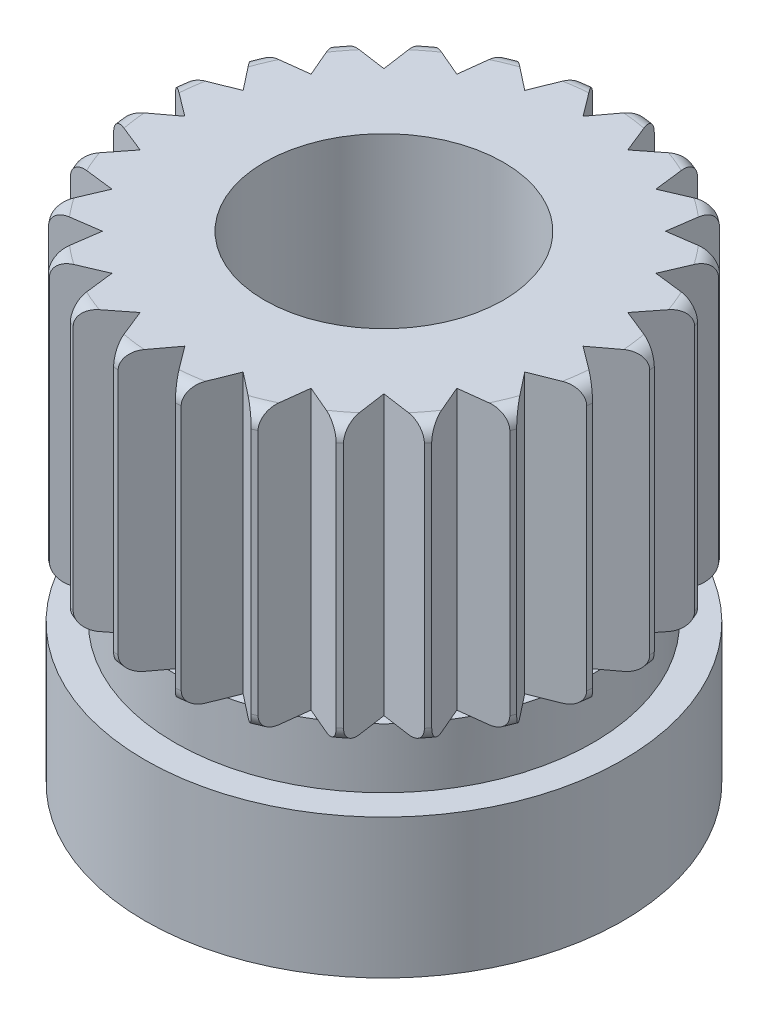
from build123d import *

# Parameters (mm, degrees)
FILLET4_R          = 0.2
CUT_EXTRUDE3_DEPTH = 3.5
CIRPATTERN1_COUNT  = 24
SKETCH3_R          = 1.5
CUT_EXTRUDE4_DEPTH = 8


with BuildPart() as part:
    # Sketch1 → Revolve1 (revolve)
    with BuildSketch(Plane.XY):
        Polygon((12.846617857, 60.731926631), (9.846617857, 60.731926631), (9.846617857, 54.731926631), (12.846617857, 54.731926631), (12.846617857, 56.481926631), (12.471617857, 56.481926631), (12.471617857, 57.231926631), (12.846617857, 57.231926631), align=None)
    revolve(axis=Axis((9.846617857, 60.731926631, 0), (0, -1, 0)))

    # Fillet4
    fillet4_edges = [part.edges().sort_by_distance(p)[0] for p in [
        (6.846617857, 60.731926631, 0),
        (6.846617857, 57.231926631, 0),
    ]]
    fillet(fillet4_edges, radius=FILLET4_R)

    # Sketch2 → Cut-Extrude3 (cut)
    with BuildSketch(Plane(origin=(0, 60.731926631, 0), x_dir=(1, 0, 0), z_dir=(0, 1, 0))):
        Polygon((9.396617857, 3.1), (9.846617857, 2.5), (10.296617857, 3.1), align=None)
    cut_extrude3 = extrude(amount=-CUT_EXTRUDE3_DEPTH, mode=Mode.SUBTRACT)

    # CirPattern1: Cut-Extrude3 ×24 about axis
    cirpattern1_axis = Axis((9.846617857, 0, 0), (0, 1, 0))
    for i in range(1, CIRPATTERN1_COUNT):
        add(cut_extrude3.rotate(cirpattern1_axis, i * 360 / CIRPATTERN1_COUNT), mode=Mode.SUBTRACT)

    # Sketch3 → Cut-Extrude4 (cut)
    with BuildSketch(Plane(origin=(0, 60.731926631, 0), x_dir=(1, 0, 0), z_dir=(0, 1, 0))):
        with Locations((9.846617857, 0)):
            Circle(SKETCH3_R)
    extrude(amount=-CUT_EXTRUDE4_DEPTH, mode=Mode.SUBTRACT)


solid = part.part
